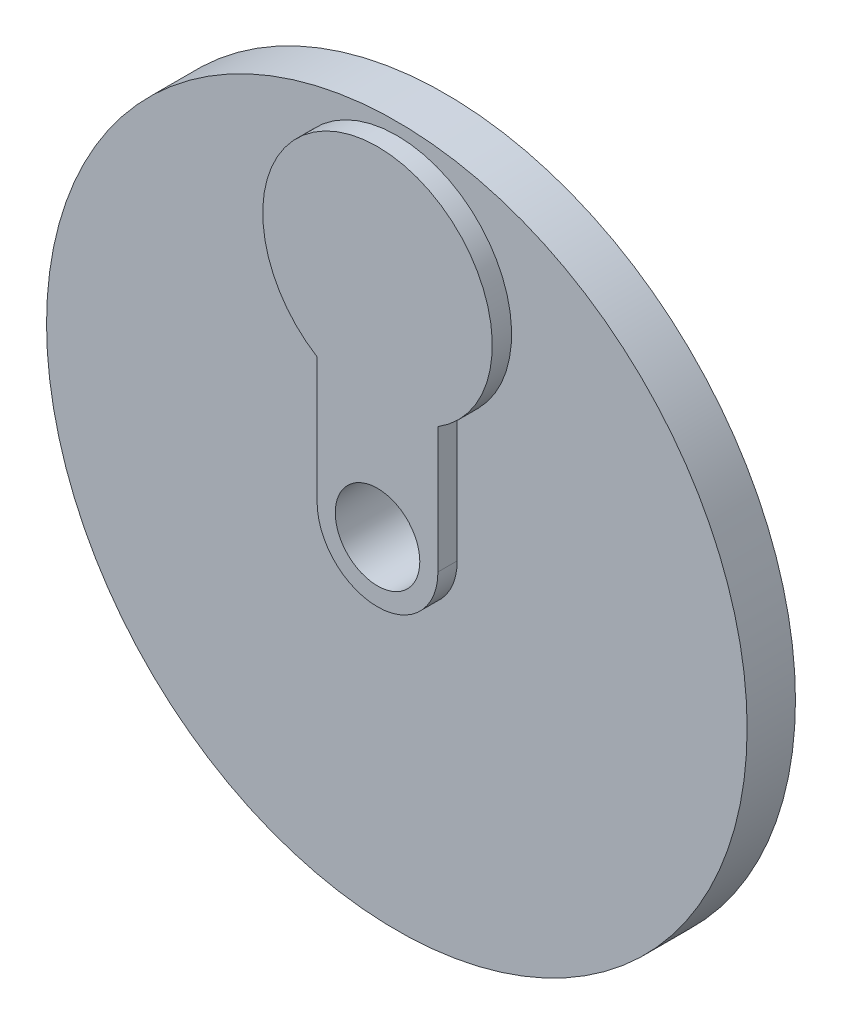
from build123d import *

# Parameters (mm, degrees)
SKETCH_1_R          = 14.5
EXTRUDE_1_DEPTH     = 2
EXTRUDE_START       = 2
EXTRUDE_2_DEPTH     = 0.8
SKETCH_1_4_R        = 1.75
CUT_EXTRUDE_1_DEPTH = 2.8


with BuildPart() as part:
    # Sketch 1 → Extrude 1 (new body)
    with BuildSketch(Plane.XY):
        with Locations((0, -9.25)):
            Circle(SKETCH_1_R)
    extrude(amount=EXTRUDE_1_DEPTH)

    # Sketch 1_3 → Extrude 2 (add)
    with BuildSketch(Plane.XY.offset(EXTRUDE_START)):
        with BuildLine():
            Line((-2.5, -4.038873605), (-2.5, -9.25))
            ThreePointArc((-2.5, -9.25), (0, -11.75), (2.5, -9.25))
            Line((2.5, -9.25), (2.5, -4.038873605))
            ThreePointArc((2.5, -4.038873605), (0, 4.75), (-2.5, -4.038873605))
        make_face()
    extrude(amount=EXTRUDE_2_DEPTH)

    # Sketch 1_4 → Cut-Extrude 1 (cut)
    with BuildSketch(Plane.XY):
        with Locations((0, -9.25)):
            Circle(SKETCH_1_4_R)
    extrude(amount=CUT_EXTRUDE_1_DEPTH, mode=Mode.SUBTRACT)


solid = part.part
